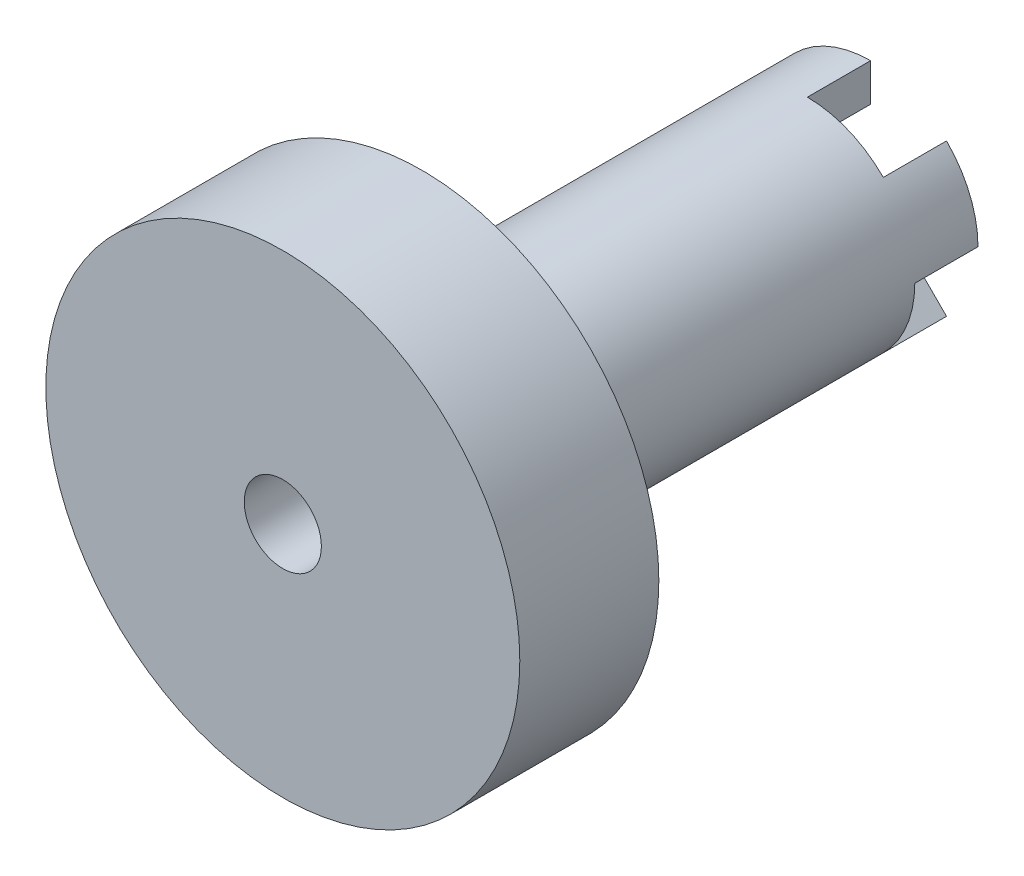
from build123d import *

# Parameters (mm, degrees)
SKETCH1_R           = 4.318
BOSS_EXTRUDE1_DEPTH = 21.082
SKETCH2_R           = 9.525
BOSS_EXTRUDE2_DEPTH = 5.588
BOSS_EXTRUDE3_DEPTH = 2.54
SKETCH6_R           = 1.55
CUT_EXTRUDE1_DEPTH  = 24.622


with BuildPart() as part:
    # Sketch1 → Boss-Extrude1 (new body)
    with BuildSketch(Plane.XY):
        Circle(SKETCH1_R)
    extrude(amount=-BOSS_EXTRUDE1_DEPTH)

    # Sketch2 → Boss-Extrude2 (add)
    with BuildSketch(Plane.XY):
        Circle(SKETCH2_R)
    extrude(amount=-BOSS_EXTRUDE2_DEPTH)

    # Sketch3 → Boss-Extrude3 (add)
    with BuildSketch(Plane(origin=(0, 0, -21.082), x_dir=(-1, 0, 0), z_dir=(0, 0, -1))):
        with BuildLine():
            Line((1.979898987, -1.979898987), (3.053287081, -3.053287081))
            ThreePointArc((3.053287081, -3.053287081), (3.989311821, -1.652427061), (4.318, 0))
            Line((4.318, 0), (2.8, 0))
            ThreePointArc((2.8, 0), (2.586862691, -1.071513611), (1.979898987, -1.979898987))
        make_face()
        with BuildLine():
            ThreePointArc((-3.053287081, 3.053287081), (-3.989311821, 1.652427061), (-4.318, 0))
            Line((-4.318, 0), (-2.8, 0))
            ThreePointArc((-2.8, 0), (-2.586862691, 1.071513611), (-1.979898987, 1.979898987))
            Line((-1.979898987, 1.979898987), (-3.053287081, 3.053287081))
        make_face()
        with BuildLine():
            ThreePointArc((-3.053287081, -3.053287081), (-1.652427061, -3.989311821), (0, -4.318))
            Line((0, -4.318), (0, -2.8))
            ThreePointArc((0, -2.8), (-1.071513611, -2.586862691), (-1.979898987, -1.979898987))
            Line((-1.979898987, -1.979898987), (-3.053287081, -3.053287081))
        make_face()
        with BuildLine():
            Line((0, 4.318), (0, 2.8))
            ThreePointArc((0, 2.8), (1.071513611, 2.586862691), (1.979898987, 1.979898987))
            Line((1.979898987, 1.979898987), (3.053287081, 3.053287081))
            ThreePointArc((3.053287081, 3.053287081), (1.652427061, 3.989311821), (0, 4.318))
        make_face()
    extrude(amount=BOSS_EXTRUDE3_DEPTH)

    # Sketch6 → Cut-Extrude1 (cut, through all)
    with BuildSketch(Plane.XY):
        Circle(SKETCH6_R)
    extrude(amount=-CUT_EXTRUDE1_DEPTH, mode=Mode.SUBTRACT)


solid = part.part
